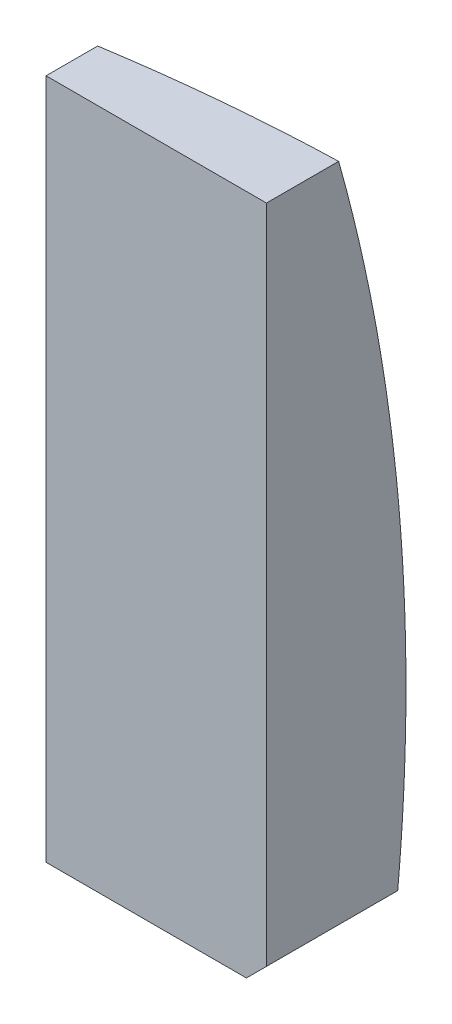
from build123d import *

# Parameters (mm, degrees)
SKETCH_2_OUTSIDE_W   = 37.95
SKETCH_2_OUTSIDE_H   = 37.95
SKETCH_2_OUTSIDE_W_2 = 5.5
SKETCH_2_OUTSIDE_H_2 = 17
CUT_EXTRUDE_1_DEPTH  = 4.5
CHAMFER_3_SIZE       = 0.5


with BuildPart() as part:
    # Эскиз1 → Повернуть1 (revolve)
    with BuildSketch(Plane(origin=(0, 0, 0), x_dir=(1, 0, 0), z_dir=(0, 1, 0))):
        with BuildLine():
            Line((14, 0), (14, 1.276685932))
            ThreePointArc((14, 1.276685932), (7.087720463, 2.940710488), (0, 3.5))
            Line((0, 3.5), (0, 0))
            Line((0, 0), (14, 0))
        make_face()
    revolve(axis=Axis((0, 0, -3.5), (0, 0, 1)))

    # Эскиз2 outside → Вырез-Вытянуть1 (cut, through all)
    with BuildSketch(Plane.XY):
        Rectangle(SKETCH_2_OUTSIDE_W, SKETCH_2_OUTSIDE_H)
        with Locations((-4.05, 3.7)):
            Rectangle(SKETCH_2_OUTSIDE_W_2, SKETCH_2_OUTSIDE_H_2, mode=Mode.SUBTRACT)
    extrude(amount=-CUT_EXTRUDE_1_DEPTH, mode=Mode.SUBTRACT)

    # Фаска3
    chamfer_3_edges = [part.edges().sort_by_distance(p)[0] for p in [
        (-1.3, -4.8, -1.61277204),
    ]]
    chamfer(chamfer_3_edges, length=CHAMFER_3_SIZE)


solid = part.part
